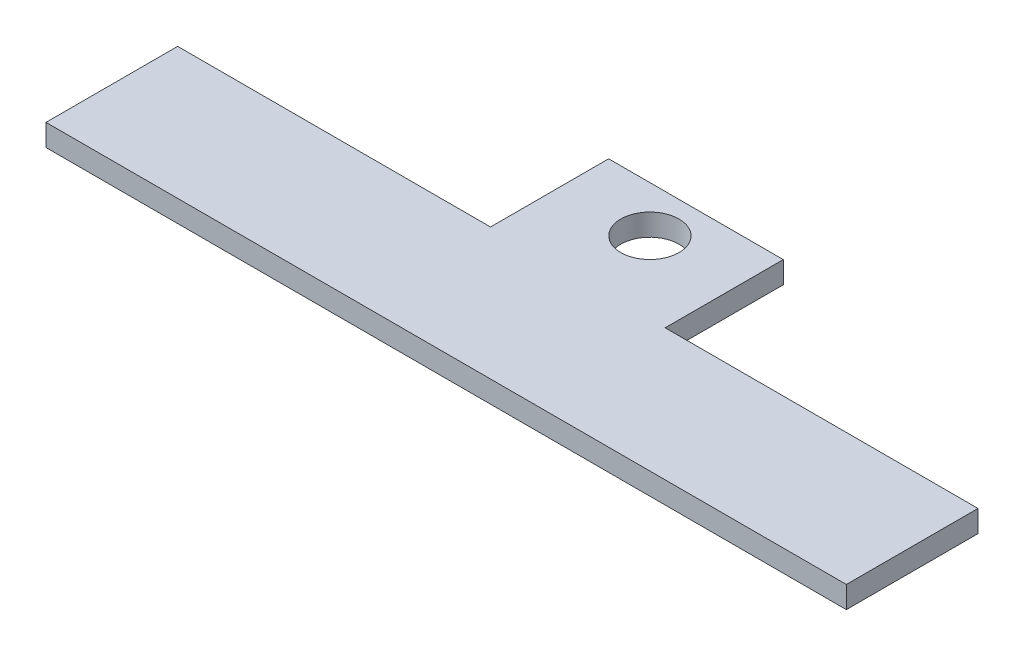
from build123d import *

# Parameters (mm, degrees)
SKETCH_1_R      = 2
EXTRUDE_1_DEPTH = 1.5


with BuildPart() as part:
    # Эскиз1 → Бобышка-Вытянуть1 (new body)
    with BuildSketch(Plane(origin=(0, 0, 0), x_dir=(1, 0, 0), z_dir=(0, 1, 0))):
        Polygon((0, 9.046468405), (21.5, 9.046468405), (21.5, 17.164912407), (33.5, 17.164912407), (33.5, 9.046468405), (55, 9.046468405), (55, 0), (0, 0), align=None)
        with Locations((27.5, 14)):
            Circle(SKETCH_1_R, mode=Mode.SUBTRACT)
    extrude(amount=EXTRUDE_1_DEPTH)


solid = part.part
